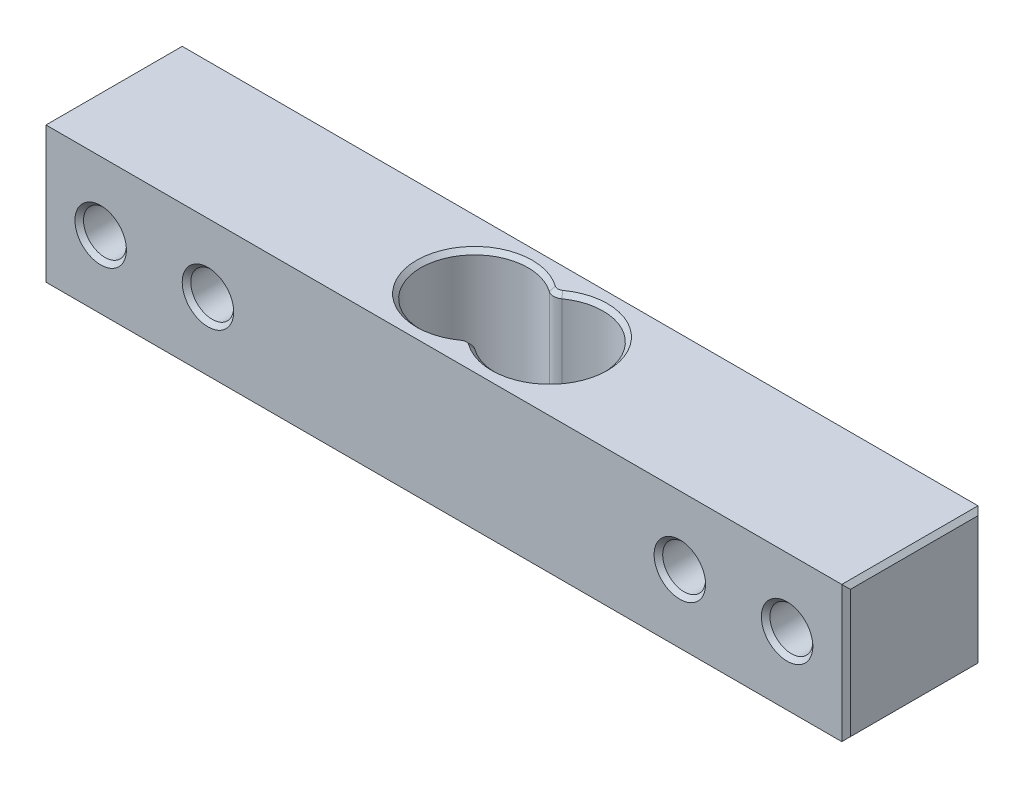
from build123d import *

# Parameters (mm, degrees)
SKETCH1_W           = 75
SKETCH1_H           = 12.7
SKETCH1_R           = 2
BOSS_EXTRUDE1_DEPTH = 12.7
CUT_EXTRUDE1_REACH  = 43.579
FILLET1_R           = 1
CHAMFER1_SIZE       = 0.4


with BuildPart() as part:
    # Sketch1 → Boss-Extrude1 (new body)
    with BuildSketch(Plane.XY):
        Rectangle(SKETCH1_W, SKETCH1_H)
        with Locations((-32, 0)):
            Circle(SKETCH1_R, mode=Mode.SUBTRACT)
        with Locations((-22, 0)):
            Circle(SKETCH1_R, mode=Mode.SUBTRACT)
        with Locations((22, 0)):
            Circle(SKETCH1_R, mode=Mode.SUBTRACT)
        with Locations((32, 0)):
            Circle(SKETCH1_R, mode=Mode.SUBTRACT)
    extrude(amount=BOSS_EXTRUDE1_DEPTH)

    # Sketch2 → Cut-Extrude1 (cut, up to next)
    with BuildSketch(Plane(origin=(0, 6.35, 0), x_dir=(1, 0, 0), z_dir=(0, 1, 0)), mode=Mode.PRIVATE) as cut_extrude1_sk1:
        with BuildLine():
            ThreePointArc((0, -2.779285786), (-8.5, -6.35), (0, -9.920714214))
            ThreePointArc((0, -9.920714214), (8.5, -6.35), (0, -2.779285786))
        make_face()
    cut_extrude1_tool1 = extrude(cut_extrude1_sk1.sketch, amount=-CUT_EXTRUDE1_REACH, mode=Mode.PRIVATE) & part.part
    add(cut_extrude1_tool1.solids().sort_by_distance((0, 6.35, 6.35))[0], mode=Mode.SUBTRACT)

    # Fillet1
    fillet1_edges = [part.edges().sort_by_distance(p)[0] for p in [
        (0, 0, 9.920714214),
        (0, 0, 2.779285786),
    ]]
    fillet(fillet1_edges, radius=FILLET1_R)

    # Chamfer1
    chamfer1_edges = [part.edges().sort_by_distance(p)[0] for p in [
        (8.5, -6.35, 6.35),
        (0, -6.35, 10.223397172),
        (0, -6.35, 2.476602828),
        (-8.5, -6.35, 6.35),
        (8.5, 6.35, 6.35),
        (0, 6.35, 2.476602828),
        (0, 6.35, 10.223397172),
        (-8.5, 6.35, 6.35),
        (-37.5, 6.35, 6.35),
        (-37.5, 0, 12.7),
        (-37.5, -6.35, 6.35),
        (-37.5, 0, 0),
        (37.5, -6.35, 6.35),
        (37.5, 0, 12.7),
        (37.5, 6.35, 6.35),
        (37.5, 0, 0),
        (30, 0, 0),
        (30, 0, 12.7),
        (20, 0, 0),
        (20, 0, 12.7),
        (-24, 0, 0),
        (-24, 0, 12.7),
        (-34, 0, 0),
        (-34, 0, 12.7),
    ]]
    chamfer(chamfer1_edges, length=CHAMFER1_SIZE)


solid = part.part
